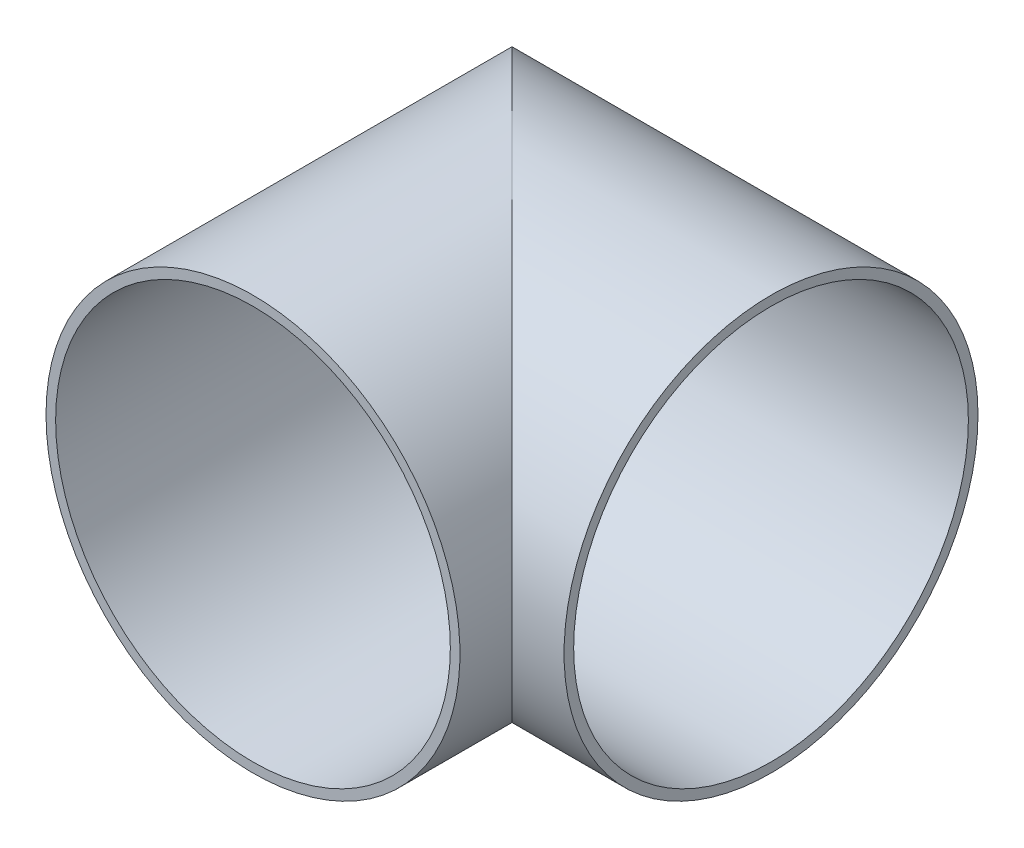
from build123d import *

# Parameters (mm, degrees)
SKETCH3_R   = 26.63931726
SKETCH3_R_2 = 25.4


with BuildPart() as part:
    # Sweep2: sweep along a path in Sketch2
    with BuildLine(Plane(origin=(0, 0, 0), x_dir=(1, 0, 0), z_dir=(0, 1, 0))) as sweep2_path:
        Line((0, -24.405392997), (0, 8.932107003))
        Line((0, 8.932107003), (33.3375, 8.932107003))
    # Sketch3 → Sweep2 (sweep)
    with BuildSketch(Plane(origin=(33.3375, 0, -8.932107003), x_dir=(0, 0, -1), z_dir=(1, 0, 0))):
        Circle(SKETCH3_R)
        Circle(SKETCH3_R_2, mode=Mode.SUBTRACT)
    sweep(path=sweep2_path.line, transition=Transition.RIGHT)


solid = part.part
